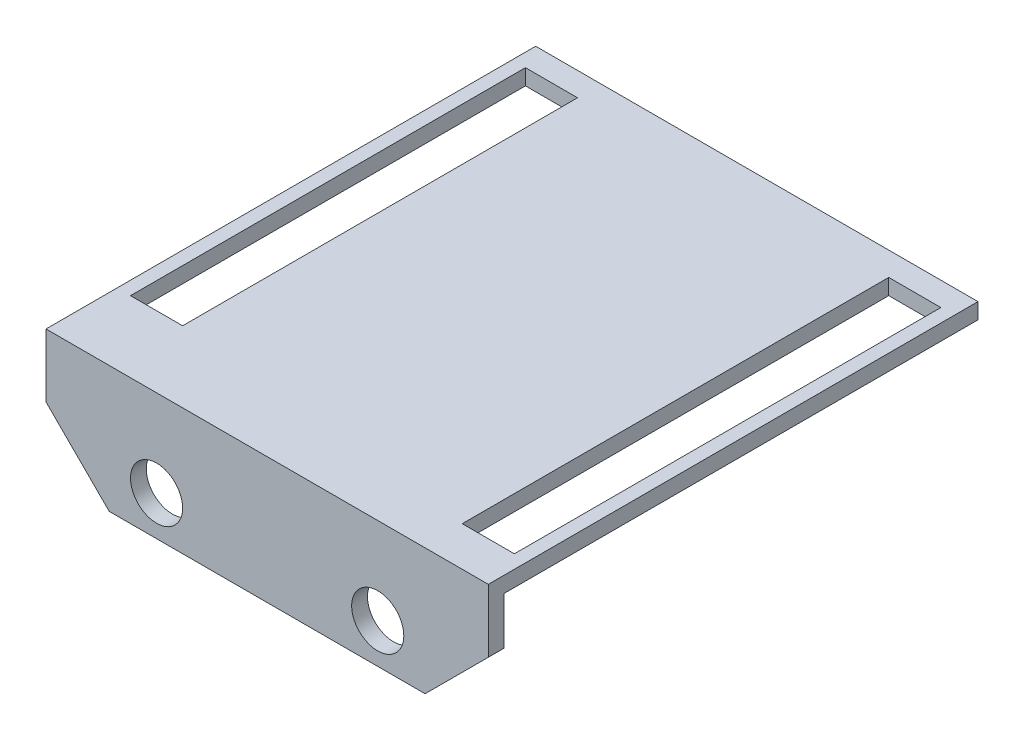
from build123d import *

# Parameters (mm, degrees)
SKETCH1_W           = 28
SKETCH1_H           = 8
BOSS_EXTRUDE1_DEPTH = 1
SKETCH2_W           = 28
SKETCH2_H           = 1
BOSS_EXTRUDE2_DEPTH = 30
SKETCH3_R           = 1.65
CUT_EXTRUDE1_DEPTH  = 1
CHAMFER1_SIZE       = 4
SKETCH4_W           = 3.3
SKETCH4_H           = 27
SKETCH4_H_2         = 25
CUT_EXTRUDE2_DEPTH  = 10


with BuildPart() as part:
    # Sketch1 → Boss-Extrude1 (new body)
    with BuildSketch(Plane.XY):
        Rectangle(SKETCH1_W, SKETCH1_H)
    extrude(amount=BOSS_EXTRUDE1_DEPTH)

    # Sketch2 → Boss-Extrude2 (add)
    with BuildSketch(Plane(origin=(0, 0, 0), x_dir=(-1, 0, 0), z_dir=(0, 0, -1))):
        with Locations((0, 3.5)):
            Rectangle(SKETCH2_W, SKETCH2_H)
    extrude(amount=BOSS_EXTRUDE2_DEPTH)

    # Sketch3 → Cut-Extrude1 (cut)
    with BuildSketch(Plane.XY.offset(1)):
        with Locations((-7, -1.5)):
            Circle(SKETCH3_R)
        with Locations((7, -1.5)):
            Circle(SKETCH3_R)
    extrude(amount=-CUT_EXTRUDE1_DEPTH, mode=Mode.SUBTRACT)

    # Chamfer1
    chamfer1_edges = [part.edges().sort_by_distance(p)[0] for p in [
        (14, -4, 0.5),
        (-14, -4, 0.5),
    ]]
    chamfer(chamfer1_edges, length=CHAMFER1_SIZE)

    # Sketch4 → Cut-Extrude2 (cut)
    with BuildSketch(Plane(origin=(0, 4, 0), x_dir=(1, 0, 0), z_dir=(0, 1, 0))):
        with Locations((11.5, 15)):
            Rectangle(SKETCH4_W, SKETCH4_H)
        with Locations((-11.5, 16)):
            Rectangle(SKETCH4_W, SKETCH4_H_2)
    extrude(amount=-CUT_EXTRUDE2_DEPTH, mode=Mode.SUBTRACT)


solid = part.part
